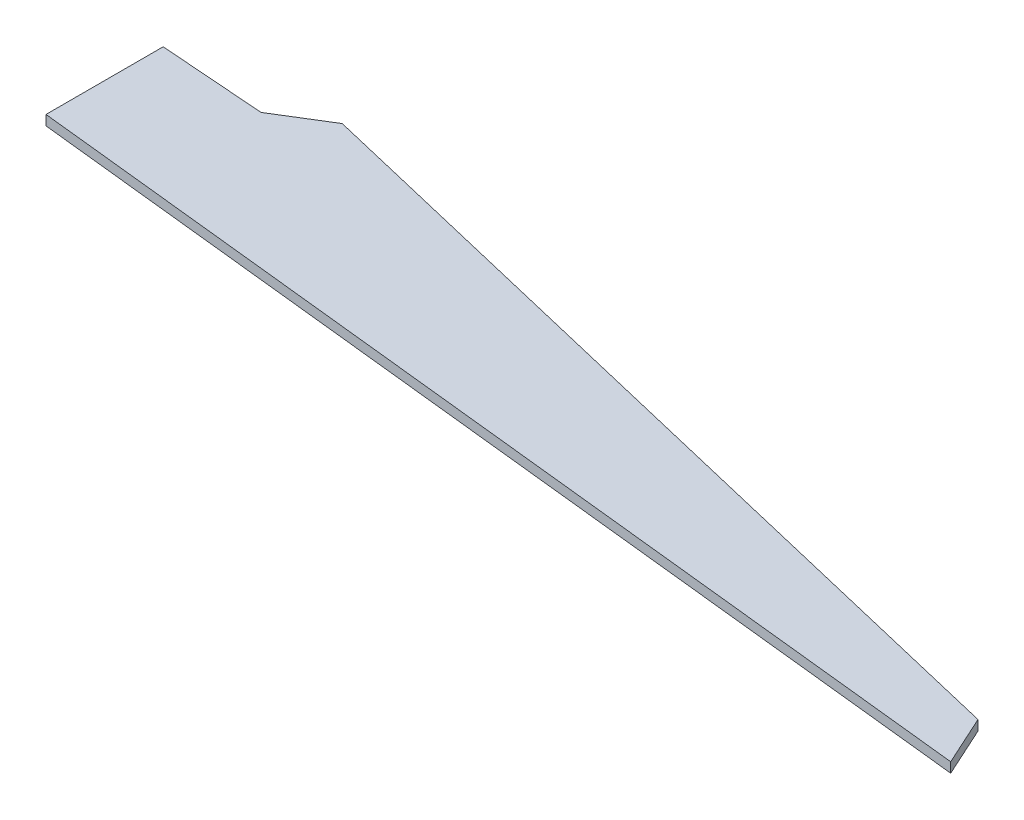
from build123d import *

# Parameters (mm, degrees)
BOSS_EXTRUDE1_DEPTH = 75


with BuildPart() as part:
    # Sketch1 → Boss-Extrude1 (new body)
    with BuildSketch(Plane(origin=(0, 0, 0), x_dir=(1, 0, 0), z_dir=(0, 1, 0))):
        Polygon((1278.788360718, 1068.317197863), (899.886687265, 834.953700601), (102.114472392, 894.615188825), (102.114472392, 10.912888966), (204.228944784, 0), (7741.310561314, -805.481660729), (7568.533892713, -426.783515384), align=None)
    extrude(amount=BOSS_EXTRUDE1_DEPTH)


solid = part.part
